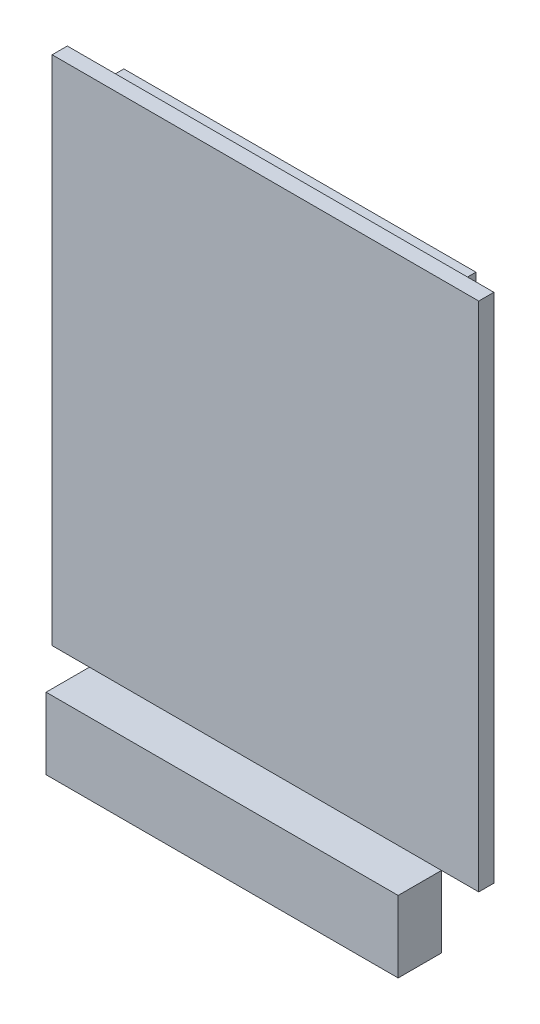
from build123d import *

# Parameters (mm, degrees)
SKETCH1_W           = 50.0126
SKETCH1_H           = 59.9948
BOSS_EXTRUDE1_DEPTH = 1.778
SKETCH2_W           = 41.275
SKETCH2_H           = 8.382
BOSS_EXTRUDE2_DEPTH = 5.08
SKETCH3_W           = 41.275
SKETCH3_H           = 5.08
BOSS_EXTRUDE3_DEPTH = 2.2606


with BuildPart() as part:
    # Sketch1 → Boss-Extrude1 (new body)
    with BuildSketch(Plane.XY):
        with Locations((25.0063, 29.9974)):
            Rectangle(SKETCH1_W, SKETCH1_H)
    extrude(amount=BOSS_EXTRUDE1_DEPTH)

    # Sketch3 → Boss-Extrude3 (add)
    with BuildSketch(Plane(origin=(0, 0, 0), x_dir=(-1, 0, 0), z_dir=(0, 0, -1))):
        with Locations((-25.0063, 56.1848)):
            Rectangle(SKETCH3_W, SKETCH3_H)
    extrude(amount=BOSS_EXTRUDE3_DEPTH)


with BuildPart() as body_2:
    # Sketch2 → Boss-Extrude2 (new body)
    with BuildSketch(Plane.XY.offset(1.778)):
        with Locations((25.0063, -4.191)):
            Rectangle(SKETCH2_W, SKETCH2_H)
    extrude(amount=BOSS_EXTRUDE2_DEPTH)


solid = Compound([part.part, body_2.part])
